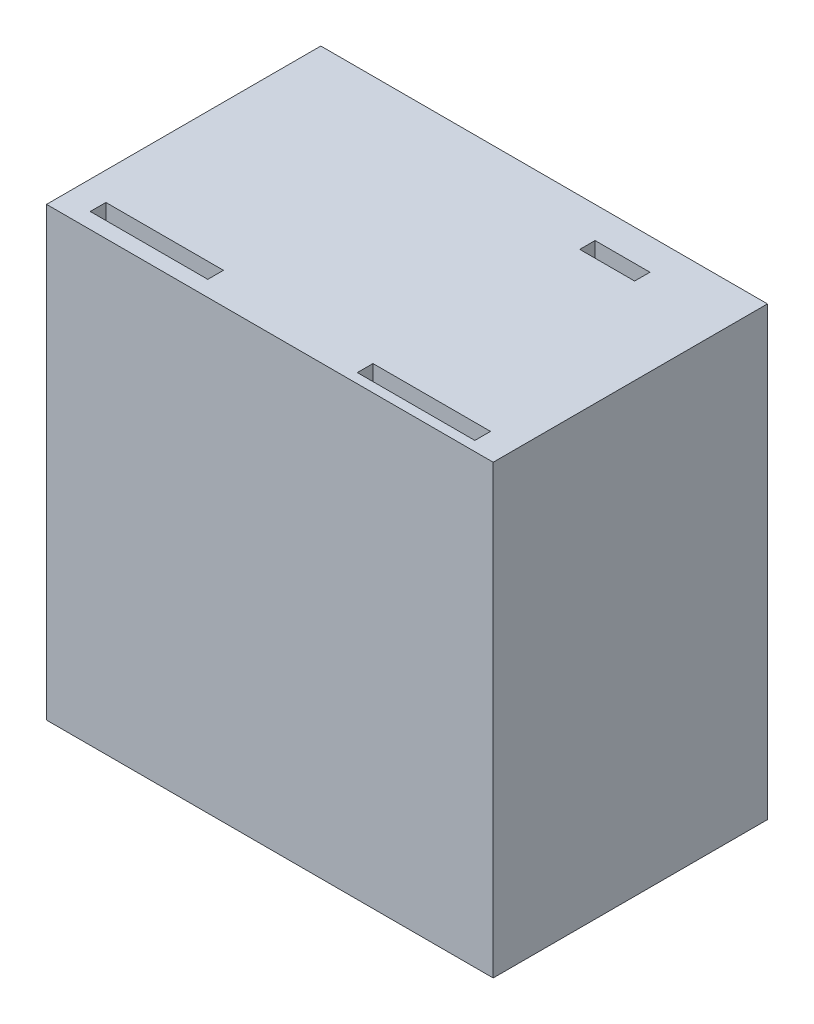
from build123d import *

# Parameters (mm, degrees)
SKETCH2_W           = 57
SKETCH2_H           = 57
BOSS_EXTRUDE1_DEPTH = 35
SKETCH3_W           = 15
SKETCH3_H           = 2
CUT_EXTRUDE1_DEPTH  = 60
SKETCH4_W           = 42
SKETCH4_H           = 42
CUT_EXTRUDE2_DEPTH  = 28
CUT_EXTRUDE4_DEPTH  = 5
CUT_EXTRUDE5_DEPTH  = 10
CUT_EXTRUDE6_DEPTH  = 5
SKETCH13_W          = 7
SKETCH13_H          = 1.952566844
CUT_EXTRUDE8_DEPTH  = 12


with BuildPart() as part:
    # Sketch2 → Boss-Extrude1 (new body)
    with BuildSketch(Plane.XY):
        with Locations((-5.733009709, -0.737864078)):
            Rectangle(SKETCH2_W, SKETCH2_H)
    extrude(amount=BOSS_EXTRUDE1_DEPTH)

    # Sketch3 → Cut-Extrude1 (cut)
    with BuildSketch(Plane(origin=(0, 27.762135922, 0), x_dir=(1, 0, 0), z_dir=(0, 1, 0))):
        with Locations((-23.156416284, -32)):
            Rectangle(SKETCH3_W, SKETCH3_H)
        with Locations((11.686990291, -32.761209032)):
            Rectangle(SKETCH3_W, SKETCH3_H)
    extrude(amount=-CUT_EXTRUDE1_DEPTH, mode=Mode.SUBTRACT)

    # Sketch4 → Cut-Extrude2 (cut)
    with BuildSketch(Plane(origin=(0, 0, 0), x_dir=(-1, 0, 0), z_dir=(0, 0, -1))):
        with Locations((5.733009709, -0.737864078)):
            Rectangle(SKETCH4_W, SKETCH4_H)
    extrude(amount=-CUT_EXTRUDE2_DEPTH, mode=Mode.SUBTRACT)

    # Sketch5 → Cut-Extrude4 (cut)
    with BuildSketch(Plane(origin=(0, -21.737864078, 0), x_dir=(1, 0, 0), z_dir=(0, 1, 0))):
        with BuildLine():
            Line((2.766990291, -11), (2.766990291, 0))
            Line((2.766990291, 0), (-14.233009709, 0))
            Line((-14.233009709, 0), (-14.233009709, -11))
            ThreePointArc((-14.233009709, -11), (-5.733009709, -19.5), (2.766990291, -11))
        make_face()
    extrude(amount=-CUT_EXTRUDE4_DEPTH, mode=Mode.SUBTRACT)

    # Sketch7 → Cut-Extrude5 (cut)
    with BuildSketch(Plane(origin=(-26.733009709, 0, 0), x_dir=(0, 0, -1), z_dir=(1, 0, 0))):
        with BuildLine():
            Line((-11, -9.237864078), (0, -9.237864078))
            Line((0, -9.237864078), (0, 7.762135922))
            Line((0, 7.762135922), (-11, 7.762135922))
            ThreePointArc((-11, 7.762135922), (-19.5, -0.737864078), (-11, -9.237864078))
        make_face()
    extrude(amount=-CUT_EXTRUDE5_DEPTH, mode=Mode.SUBTRACT)

    # Sketch8 → Cut-Extrude6 (cut)
    with BuildSketch(Plane(origin=(0, -26.737864078, 0), x_dir=(1, 0, 0), z_dir=(0, 1, 0))):
        with BuildLine():
            Line((-14.233009709, 0), (2.766990291, 0))
            Line((2.766990291, 0), (2.766990291, -11))
            ThreePointArc((2.766990291, -11), (-5.733009709, -19.5), (-14.233009709, -11))
            Line((-14.233009709, -11), (-14.233009709, 0))
        make_face()
    extrude(amount=-CUT_EXTRUDE6_DEPTH, mode=Mode.SUBTRACT)

    # Sketch13 → Cut-Extrude8 (cut)
    with BuildSketch(Plane(origin=(0, 27.762135922, 0), x_dir=(1, 0, 0), z_dir=(0, 1, 0))):
        with Locations((8.266990291, -4.976283422)):
            Rectangle(SKETCH13_W, SKETCH13_H)
    extrude(amount=-CUT_EXTRUDE8_DEPTH, mode=Mode.SUBTRACT)


solid = part.part
